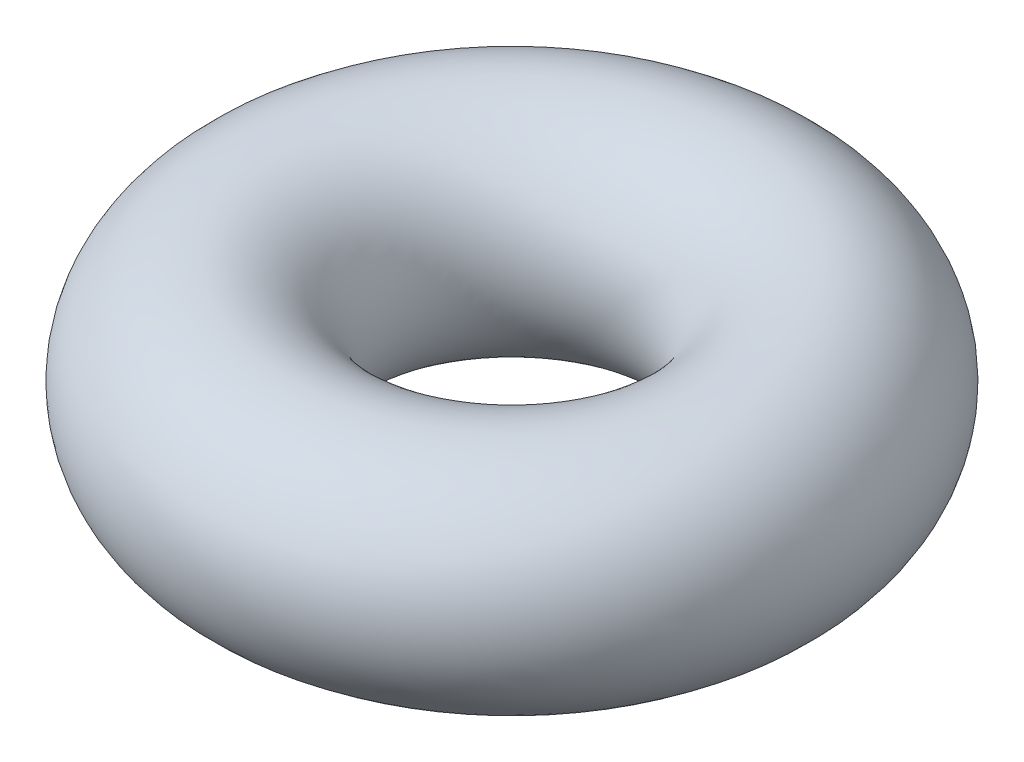
from build123d import *

# Parameters (mm, degrees)
SKETCH2_R = 0.889


with BuildPart() as part:
    # Sketch2 → Revolve1 (revolve)
    with BuildSketch(Plane.XY):
        with Locations((-1.778, 0)):
            Circle(SKETCH2_R)
    revolve(axis=Axis((0, 0, 0), (0, 1, 0)))


solid = part.part
